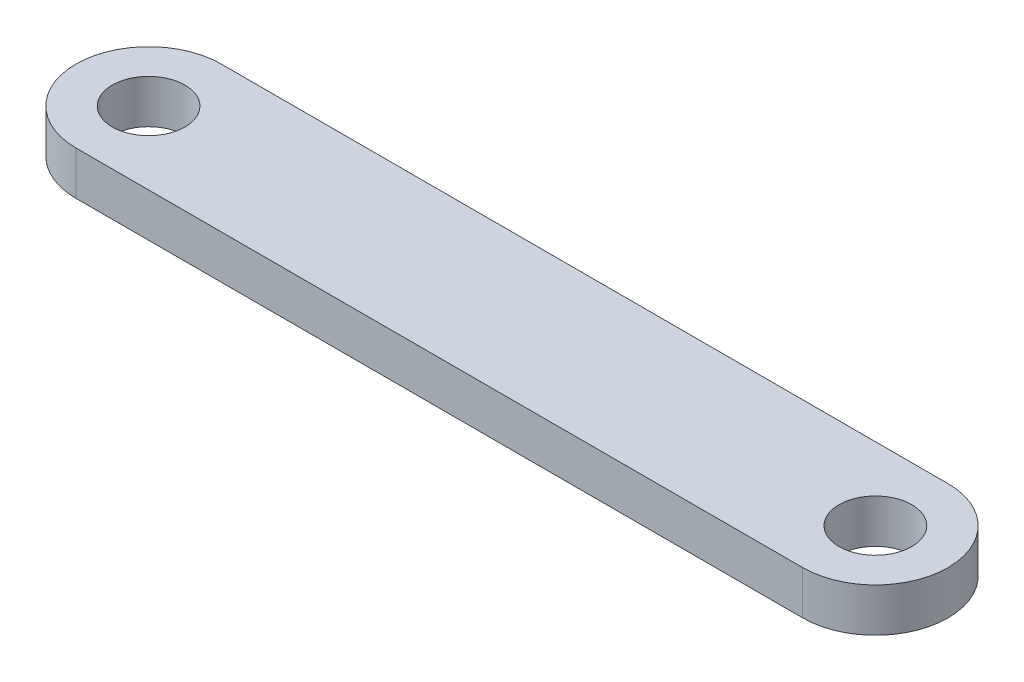
from build123d import *

# Parameters (mm, degrees)
CROQUIS1_R              = 2.5
SALIENTE_EXTRUIR1_DEPTH = 3


with BuildPart() as part:
    # Croquis1 → Saliente-Extruir1 (new body)
    with BuildSketch(Plane(origin=(0, 0, 0), x_dir=(1, 0, 0), z_dir=(0, 1, 0))):
        with BuildLine():
            Line((-25, 5), (25, 5))
            ThreePointArc((25, 5), (30, 0), (25, -5))
            Line((25, -5), (-25, -5))
            ThreePointArc((-25, -5), (-30, 0), (-25, 5))
        make_face()
        with Locations((-25, 0)):
            Circle(CROQUIS1_R, mode=Mode.SUBTRACT)
        with Locations((25, 0)):
            Circle(CROQUIS1_R, mode=Mode.SUBTRACT)
    extrude(amount=SALIENTE_EXTRUIR1_DEPTH)


solid = part.part
